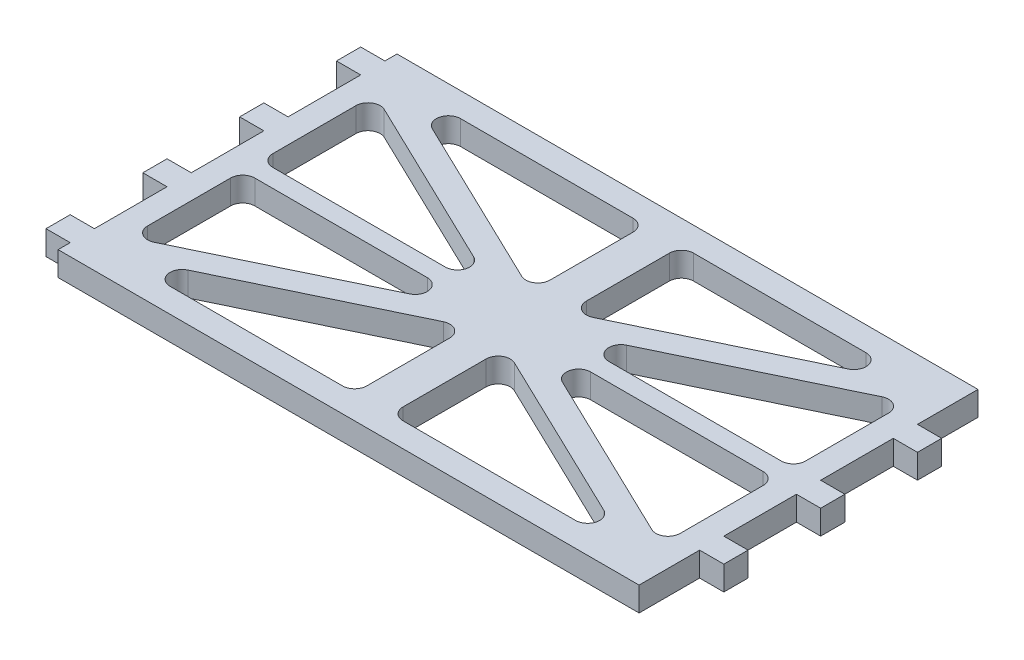
from build123d import *

# Parameters (mm, degrees)
BOSS_EXTRUDE1_DEPTH = 4
CUT_EXTRUDE1_DEPTH  = 10


with BuildPart() as part:
    # Sketch1 → Boss-Extrude1 (new body)
    with BuildSketch(Plane(origin=(0, 0, 0), x_dir=(1, 0, 0), z_dir=(0, 1, 0))):
        Polygon((-17.714285714, 14), (-17.714285714, 12), (-21.714285714, 12), (-21.714285714, 8), (-17.714285714, 8), (-17.714285714, -4), (-21.714285714, -4), (-21.714285714, -8), (-17.714285714, -8), (-17.714285714, -20), (-21.714285714, -20), (-21.714285714, -24), (-17.714285714, -24), (-17.714285714, -36), (-21.714285714, -36), (-21.714285714, -40), (-17.714285714, -40), (-17.714285714, -42), (78.285714286, -42), (78.285714286, -32), (82.285714286, -32), (82.285714286, -28), (78.285714286, -28), (78.285714286, -16), (82.285714286, -16), (82.285714286, -12), (78.285714286, -12), (78.285714286, 0), (82.285714286, 0), (82.285714286, 4), (78.285714286, 4), (78.285714286, 14), align=None)
    extrude(amount=-BOSS_EXTRUDE1_DEPTH)

    # Sketch2 → Cut-Extrude1 (cut)
    with BuildSketch(Plane(origin=(0, 0, 0), x_dir=(1, 0, 0), z_dir=(0, 1, 0))):
        with BuildLine():
            Line((-3.21150143, 10), (25.285714286, 10))
            ThreePointArc((25.285714286, 10), (26.699927848, 9.414213562), (27.285714286, 8))
            Line((27.285714286, 8), (27.285714286, -5.713648924))
            ThreePointArc((27.285714286, -5.713648924), (26.350016922, -7.40694745), (24.418454387, -7.515831009))
            Line((24.418454387, -7.515831009), (-4.078761328, 6.197817915))
            ThreePointArc((-4.078761328, 6.197817915), (-5.161419911, 8.444767259), (-3.21150143, 10))
        make_face()
        with BuildLine():
            ThreePointArc((-13.714285714, 3.213648924), (-12.77858835, 4.90694745), (-10.847025816, 5.015831009))
            Line((-10.847025816, 5.015831009), (17.6501899, -8.697817915))
            ThreePointArc((17.6501899, -8.697817915), (18.732848483, -10.944767259), (16.782930001, -12.5))
            Line((16.782930001, -12.5), (-11.714285714, -12.5))
            ThreePointArc((-11.714285714, -12.5), (-13.128499277, -11.914213562), (-13.714285714, -10.5))
            Line((-13.714285714, -10.5), (-13.714285714, 3.213648924))
        make_face()
        with BuildLine():
            ThreePointArc((-13.714285714, -17.5), (-13.128499277, -16.085786438), (-11.714285714, -15.5))
            Line((-11.714285714, -15.5), (16.782930001, -15.5))
            ThreePointArc((16.782930001, -15.5), (18.732848483, -17.055232741), (17.6501899, -19.302182085))
            Line((17.6501899, -19.302182085), (-10.847025816, -33.015831009))
            ThreePointArc((-10.847025816, -33.015831009), (-12.77858835, -32.90694745), (-13.714285714, -31.213648924))
            Line((-13.714285714, -31.213648924), (-13.714285714, -17.5))
        make_face()
        with BuildLine():
            Line((27.285714286, -36), (27.285714286, -22.286351076))
            ThreePointArc((27.285714286, -22.286351076), (26.350016922, -20.59305255), (24.418454387, -20.484168991))
            Line((24.418454387, -20.484168991), (-4.078761328, -34.197817915))
            ThreePointArc((-4.078761328, -34.197817915), (-5.161419911, -36.444767259), (-3.21150143, -38))
            Line((-3.21150143, -38), (25.285714286, -38))
            ThreePointArc((25.285714286, -38), (26.699927848, -37.414213562), (27.285714286, -36))
        make_face()
        with BuildLine():
            Line((63.782930001, -38), (35.285714286, -38))
            ThreePointArc((35.285714286, -38), (33.871500723, -37.414213562), (33.285714286, -36))
            Line((33.285714286, -36), (33.285714286, -22.286351076))
            ThreePointArc((33.285714286, -22.286351076), (34.22141165, -20.59305255), (36.152974184, -20.484168991))
            Line((36.152974184, -20.484168991), (64.6501899, -34.197817915))
            ThreePointArc((64.6501899, -34.197817915), (65.732848483, -36.444767259), (63.782930001, -38))
        make_face()
        with BuildLine():
            ThreePointArc((74.285714286, -31.213648924), (73.350016922, -32.90694745), (71.418454387, -33.015831009))
            Line((71.418454387, -33.015831009), (42.921238672, -19.302182085))
            ThreePointArc((42.921238672, -19.302182085), (41.838580089, -17.055232741), (43.78849857, -15.5))
            Line((43.78849857, -15.5), (72.285714286, -15.5))
            ThreePointArc((72.285714286, -15.5), (73.699927848, -16.085786438), (74.285714286, -17.5))
            Line((74.285714286, -17.5), (74.285714286, -31.213648924))
        make_face()
        with BuildLine():
            ThreePointArc((74.285714286, -10.5), (73.699927848, -11.914213562), (72.285714286, -12.5))
            Line((72.285714286, -12.5), (43.78849857, -12.5))
            ThreePointArc((43.78849857, -12.5), (41.838580089, -10.944767259), (42.921238672, -8.697817915))
            Line((42.921238672, -8.697817915), (71.418454387, 5.015831009))
            ThreePointArc((71.418454387, 5.015831009), (73.350016922, 4.90694745), (74.285714286, 3.213648924))
            Line((74.285714286, 3.213648924), (74.285714286, -10.5))
        make_face()
        with BuildLine():
            Line((33.285714286, 8), (33.285714286, -5.713648924))
            ThreePointArc((33.285714286, -5.713648924), (34.22141165, -7.40694745), (36.152974184, -7.515831009))
            Line((36.152974184, -7.515831009), (64.6501899, 6.197817915))
            ThreePointArc((64.6501899, 6.197817915), (65.732848483, 8.444767259), (63.782930001, 10))
            Line((63.782930001, 10), (35.285714286, 10))
            ThreePointArc((35.285714286, 10), (33.871500723, 9.414213562), (33.285714286, 8))
        make_face()
    extrude(amount=-CUT_EXTRUDE1_DEPTH, mode=Mode.SUBTRACT)


solid = part.part
